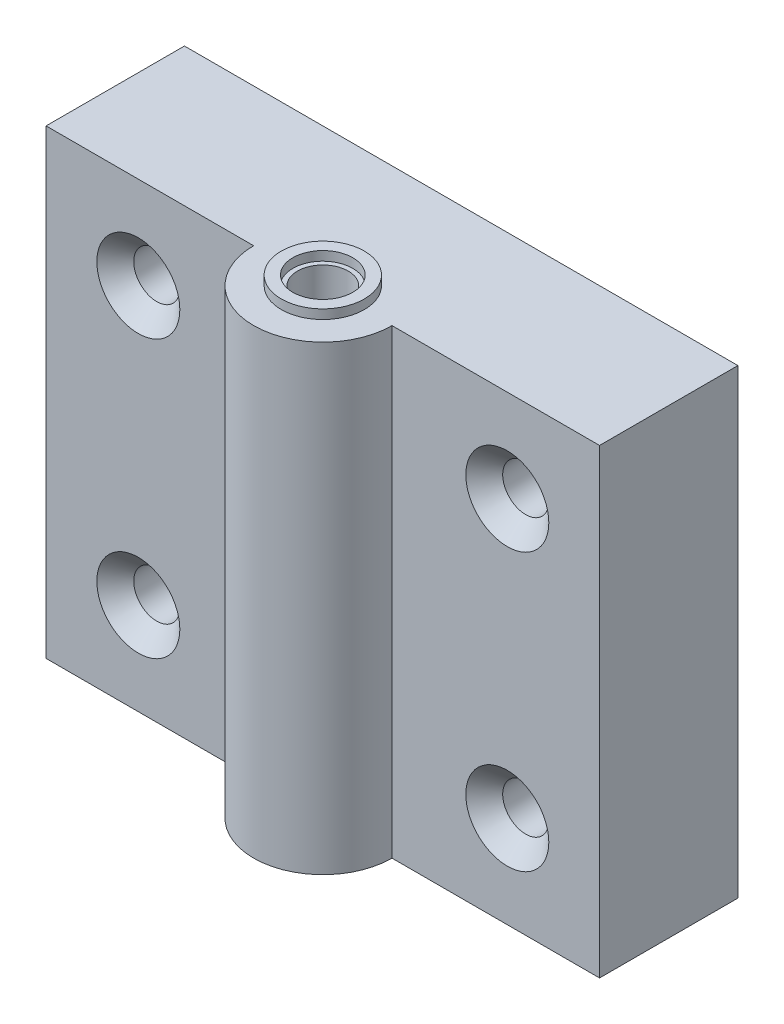
from build123d import *

# Parameters (mm, degrees)
ESQUISSE1_W                = 60
ESQUISSE1_H                = 50
BOSS_EXTRU_1_DEPTH         = 15
BOSS_EXTRU_2_DEPTH         = 50
ESQUISSE3_R                = 4.5
ESQUISSE3_R_2              = 3.25
BOSS_EXTRU_3_DEPTH         = 1
ESQUISSE4_R                = 2.75
ENL_V_MAT_EXTRU_1_DEPTH    = 50
ESQUISSE5_R                = 2.5
ENL_V_MAT_EXTRU_2_DEPTH    = 15
R_P_TITION_LIN_AIRE1_COUNT = 2
R_P_TITION_LIN_AIRE1_PITCH = 30
R_P_TITION_LIN_AIRE2_COUNT = 2
R_P_TITION_LIN_AIRE2_PITCH = 40


with BuildPart() as part:
    # Esquisse1 → Boss.-Extru.1 (new body)
    with BuildSketch(Plane.XY):
        Rectangle(ESQUISSE1_W, ESQUISSE1_H)
    extrude(amount=BOSS_EXTRU_1_DEPTH)

    # Esquisse2 → Boss.-Extru.2 (add)
    with BuildSketch(Plane(origin=(0, 25, 0), x_dir=(1, 0, 0), z_dir=(0, 1, 0))):
        with BuildLine():
            Line((-7.5, -15), (7.5, -15))
            ThreePointArc((7.5, -15), (0, -22.5), (-7.5, -15))
        make_face()
    extrude(amount=-BOSS_EXTRU_2_DEPTH)

    # Esquisse3 → Boss.-Extru.3 (add)
    with BuildSketch(Plane(origin=(0, 25, 0), x_dir=(1, 0, 0), z_dir=(0, 1, 0))):
        with Locations((0, -15)):
            Circle(ESQUISSE3_R)
        with Locations((0, -15)):
            Circle(ESQUISSE3_R_2, mode=Mode.SUBTRACT)
    extrude(amount=BOSS_EXTRU_3_DEPTH)

    # Esquisse4 → Enlèv. mat.-Extru.1 (cut)
    with BuildSketch(Plane(origin=(0, 25, 0), x_dir=(1, 0, 0), z_dir=(0, 1, 0))):
        with Locations((0, -15)):
            Circle(ESQUISSE4_R)
    extrude(amount=-ENL_V_MAT_EXTRU_1_DEPTH, mode=Mode.SUBTRACT)

    # Esquisse5 → Enlèv. mat.-Extru.2 (cut)
    with BuildSketch(Plane.XY.offset(15)):
        with Locations((-20, -15)):
            Circle(ESQUISSE5_R)
        with Locations((-20, 15)):
            Circle(ESQUISSE5_R)
        with Locations((20, -15)):
            Circle(ESQUISSE5_R)
        with Locations((20, 15)):
            Circle(ESQUISSE5_R)
    extrude(amount=-ENL_V_MAT_EXTRU_2_DEPTH, mode=Mode.SUBTRACT)

    # Esquisse13 → Enlèvement de matière-Révolution1 (revolve, cut)
    with BuildSketch(Plane.XZ.offset(15)):
        Polygon((-24.5, 15), (-22.5, 13), (-22.5, 15), align=None)
    enl_vement_de_mati_re_r_volution1 = revolve(axis=Axis((-20, -15, 15), (0, 0, -1)), mode=Mode.SUBTRACT)

    # Répétition linéaire1: Enlèvement de matière-Révolution1 ×2
    with Locations(*[(0, i * R_P_TITION_LIN_AIRE1_PITCH, 0) for i in range(1, R_P_TITION_LIN_AIRE1_COUNT)]):
        add(enl_vement_de_mati_re_r_volution1, mode=Mode.SUBTRACT)

    # Répétition linéaire2: Enlèvement de matière-Révolution1 ×2
    with Locations(*[(i * R_P_TITION_LIN_AIRE2_PITCH, 0, 0) for i in range(1, R_P_TITION_LIN_AIRE2_COUNT)]):
        add(enl_vement_de_mati_re_r_volution1, mode=Mode.SUBTRACT)

    # Répétition linéaire2 copy 1 sketch → Répétition linéaire2 copy 1 (revolve, cut)
    with BuildSketch(Plane(origin=(40, 15, 0), x_dir=(1, 0, 0), z_dir=(0, -1, 0))):
        Polygon((-24.5, 15), (-22.5, 13), (-22.5, 15), align=None)
    revolve(axis=Axis((20, 15, 15), (0, 0, -1)), mode=Mode.SUBTRACT)


solid = part.part
